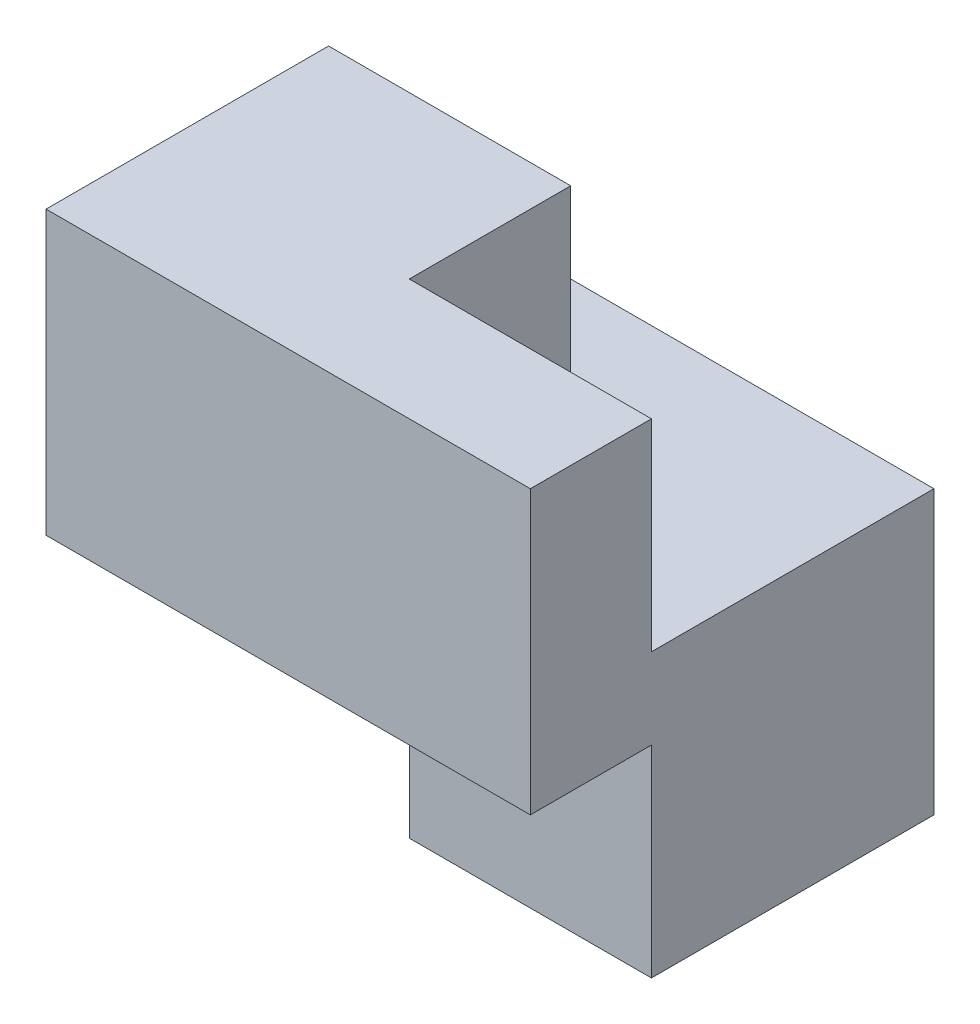
from build123d import *

# Parameters (mm, degrees)
SKETCH1_W           = 6
SKETCH1_H           = 5
BOSS_EXTRUDE1_DEPTH = 6
CUT_EXTRUDE1_DEPTH  = 2.5
CUT_EXTRUDE2_DEPTH  = 2.5


with BuildPart() as part:
    # Sketch1 → Boss-Extrude1 (new body)
    with BuildSketch(Plane(origin=(0, 0, 0), x_dir=(1, 0, 0), z_dir=(0, 1, 0))):
        Rectangle(SKETCH1_W, SKETCH1_H)
    extrude(amount=BOSS_EXTRUDE1_DEPTH)

    # Sketch2 → Cut-Extrude1 (cut)
    with BuildSketch(Plane(origin=(0, 6, 0), x_dir=(1, 0, 0), z_dir=(0, 1, 0))):
        Polygon((0, -1), (3, -1), (3, 2.5), (-3, 2.5), (-3, 1), (0, 1), align=None)
    extrude(amount=-CUT_EXTRUDE1_DEPTH, mode=Mode.SUBTRACT)

    # Sketch3 → Cut-Extrude2 (cut)
    with BuildSketch(Plane.XZ):
        Polygon((3, 1), (0, 1), (0, -1), (-3, -1), (-3, 2.5), (3, 2.5), align=None)
    extrude(amount=-CUT_EXTRUDE2_DEPTH, mode=Mode.SUBTRACT)


solid = part.part
